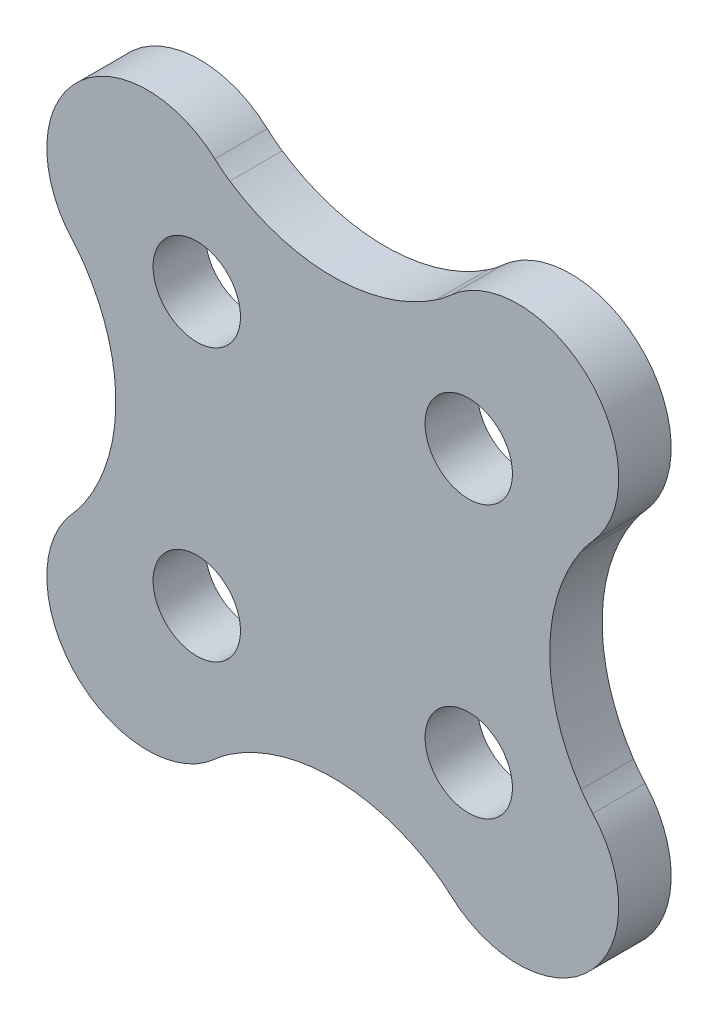
from build123d import *

# Parameters (mm, degrees)
MODEL_R         = 1
EXTRUDE_1_DEPTH = 1.2


with BuildPart() as part:
    # Model → 凸台-拉伸1 (new body)
    with BuildSketch(Plane.XY):
        with BuildLine():
            ThreePointArc((12.485683382, 19.826470809), (12.652302696, 19.686300725), (12.828649886, 19.55858496))
            ThreePointArc((12.828649886, 19.55858496), (15.184787498, 18.84198425), (17.540925109, 19.55858496))
            ThreePointArc((17.540925109, 19.55858496), (17.7172723, 19.686300725), (17.883891613, 19.826470809))
            ThreePointArc((17.883891613, 19.826470809), (21.053773782, 19.747678625), (21.132565966, 16.577796457))
            ThreePointArc((21.132565966, 16.577796457), (20.992395882, 16.411177143), (20.864680117, 16.234829953))
            ThreePointArc((20.864680117, 16.234829953), (20.148079407, 13.878692341), (20.864680117, 11.522554729))
            ThreePointArc((20.864680117, 11.522554729), (20.992395882, 11.346207539), (21.132565966, 11.179588225))
            ThreePointArc((21.132565966, 11.179588225), (21.053773782, 8.009706057), (17.883891613, 7.930913873))
            ThreePointArc((17.883891613, 7.930913873), (17.7172723, 8.071083957), (17.540925109, 8.198799722))
            ThreePointArc((17.540925109, 8.198799722), (15.184787498, 8.915400432), (12.828649886, 8.198799722))
            ThreePointArc((12.828649886, 8.198799722), (12.652302696, 8.071083957), (12.485683382, 7.930913873))
            ThreePointArc((12.485683382, 7.930913873), (9.315801214, 8.009706057), (9.237009029, 11.179588225))
            ThreePointArc((9.237009029, 11.179588225), (9.377179113, 11.346207539), (9.504894878, 11.522554729))
            ThreePointArc((9.504894878, 11.522554729), (10.221495588, 13.878692341), (9.504894878, 16.234829953))
            ThreePointArc((9.504894878, 16.234829953), (9.377179113, 16.411177143), (9.237009029, 16.577796457))
            ThreePointArc((9.237009029, 16.577796457), (9.315801214, 19.747678625), (12.485683382, 19.826470809))
        make_face()
        with Locations((18.296057335, 16.989962178)):
            Circle(MODEL_R, mode=Mode.SUBTRACT)
        with Locations((12.07351766, 16.989962178)):
            Circle(MODEL_R, mode=Mode.SUBTRACT)
        with Locations((12.07351766, 10.767422504)):
            Circle(MODEL_R, mode=Mode.SUBTRACT)
        with Locations((18.296057335, 10.767422504)):
            Circle(MODEL_R, mode=Mode.SUBTRACT)
    extrude(amount=EXTRUDE_1_DEPTH)


solid = part.part
